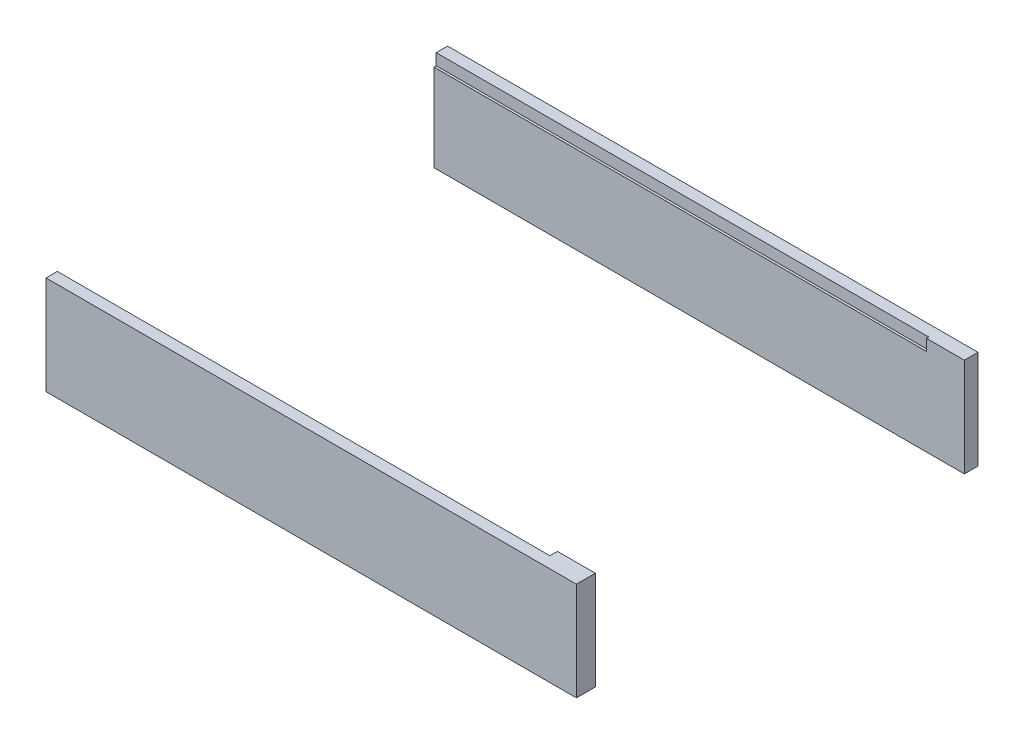
from build123d import *

# Parameters (mm, degrees)
SKETCH3_W             = 70
SKETCH3_H             = 1.8
BOSS_EXTRUDE1_DEPTH   = 13
SKETCH3_H_2           = 2.5
BOSS_EXTRUDE1_2_DEPTH = 13
SKETCH4_W             = 65
SKETCH4_H             = 1
CUT_EXTRUDE1_DEPTH    = 1.5
SKETCH5_W             = 65
SKETCH5_H             = 0.3
CUT_EXTRUDE2_DEPTH    = 1.5


with BuildPart() as part:
    # Sketch3 → Boss-Extrude1 (new body)
    with BuildSketch(Plane(origin=(0, 0, 0), x_dir=(1, 0, 0), z_dir=(0, 1, 0))):
        with Locations((-4.811320755, 1.835849057)):
            Rectangle(SKETCH3_W, SKETCH3_H)
    extrude(amount=BOSS_EXTRUDE1_DEPTH)

    # Sketch5 → Cut-Extrude2 (cut)
    with BuildSketch(Plane(origin=(0, 13, 0), x_dir=(1, 0, 0), z_dir=(0, 1, 0))):
        with Locations((-7.311320755, 1.085849057)):
            Rectangle(SKETCH5_W, SKETCH5_H)
    extrude(amount=-CUT_EXTRUDE2_DEPTH, mode=Mode.SUBTRACT)


with BuildPart() as body_2:
    # Sketch3 → Boss-Extrude1 2 (new body)
    with BuildSketch(Plane(origin=(0, 0, 0), x_dir=(1, 0, 0), z_dir=(0, 1, 0))):
        with Locations((-4.811320755, -49.014150943)):
            Rectangle(SKETCH3_W, SKETCH3_H_2)
    extrude(amount=BOSS_EXTRUDE1_2_DEPTH)

    # Sketch4 → Cut-Extrude1 (cut)
    with BuildSketch(Plane(origin=(0, 13, 0), x_dir=(1, 0, 0), z_dir=(0, 1, 0))):
        with Locations((-7.311320755, -48.264150943)):
            Rectangle(SKETCH4_W, SKETCH4_H)
    extrude(amount=-CUT_EXTRUDE1_DEPTH, mode=Mode.SUBTRACT)


solid = Compound([part.part, body_2.part])
